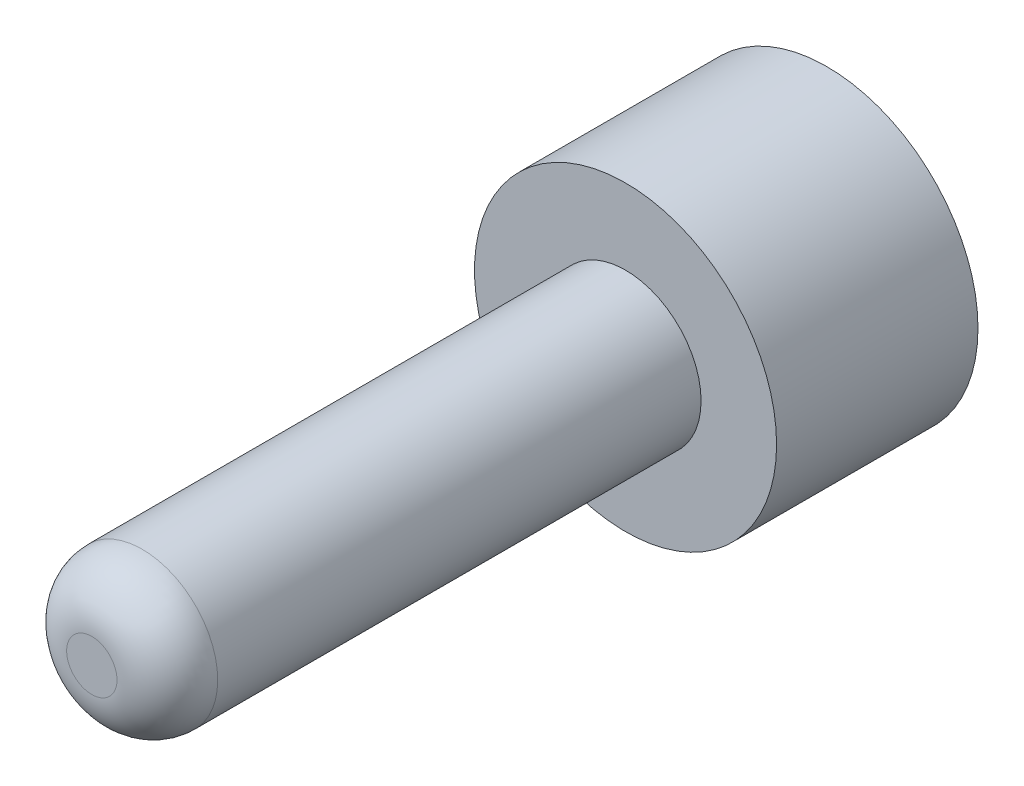
from build123d import *

# Parameters (mm, degrees)
SKETCH1_R           = 1.5
BOSS_EXTRUDE1_DEPTH = 2
SKETCH2_R           = 0.75
BOSS_EXTRUDE2_DEPTH = 5.3
FILLET1_R           = 0.5


with BuildPart() as part:
    # Sketch1 → Boss-Extrude1 (new body)
    with BuildSketch(Plane.XY):
        Circle(SKETCH1_R)
    extrude(amount=BOSS_EXTRUDE1_DEPTH)

    # Sketch2 → Boss-Extrude2 (add)
    with BuildSketch(Plane.XY.offset(2)):
        Circle(SKETCH2_R)
    extrude(amount=BOSS_EXTRUDE2_DEPTH)

    # Fillet1
    fillet1_edges = [part.edges().sort_by_distance(p)[0] for p in [
        (-0.75, 0, 7.3),
    ]]
    fillet(fillet1_edges, radius=FILLET1_R)


solid = part.part
